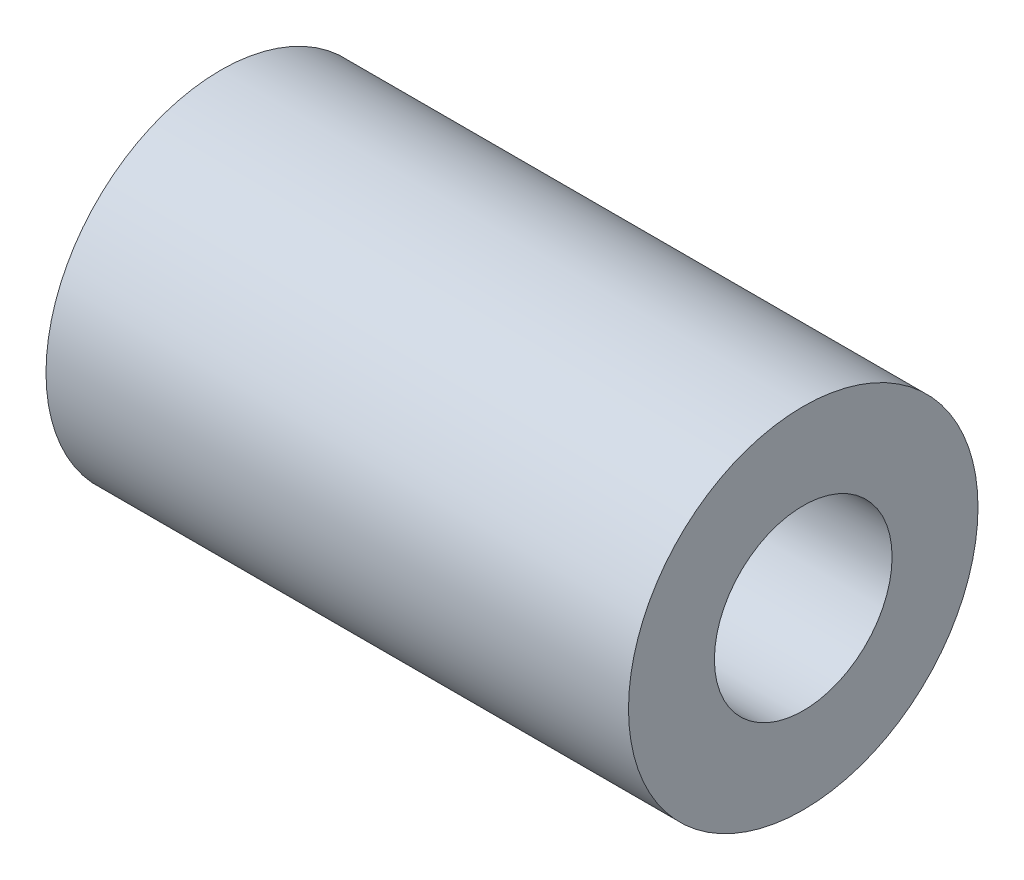
from build123d import *

# Parameters (mm, degrees)
ESQUISSE1_R      = 6
ESQUISSE1_R_2    = 3.05
EXTRUSION1_DEPTH = 10


with BuildPart() as part:
    # Esquisse1 → Extrusion1 (new body, symmetric)
    with BuildSketch(Plane(origin=(0, 0, 0), x_dir=(0, 0, -1), z_dir=(1, 0, 0))):
        Circle(ESQUISSE1_R)
        Circle(ESQUISSE1_R_2, mode=Mode.SUBTRACT)
    extrude(amount=EXTRUSION1_DEPTH, both=True)


solid = part.part
